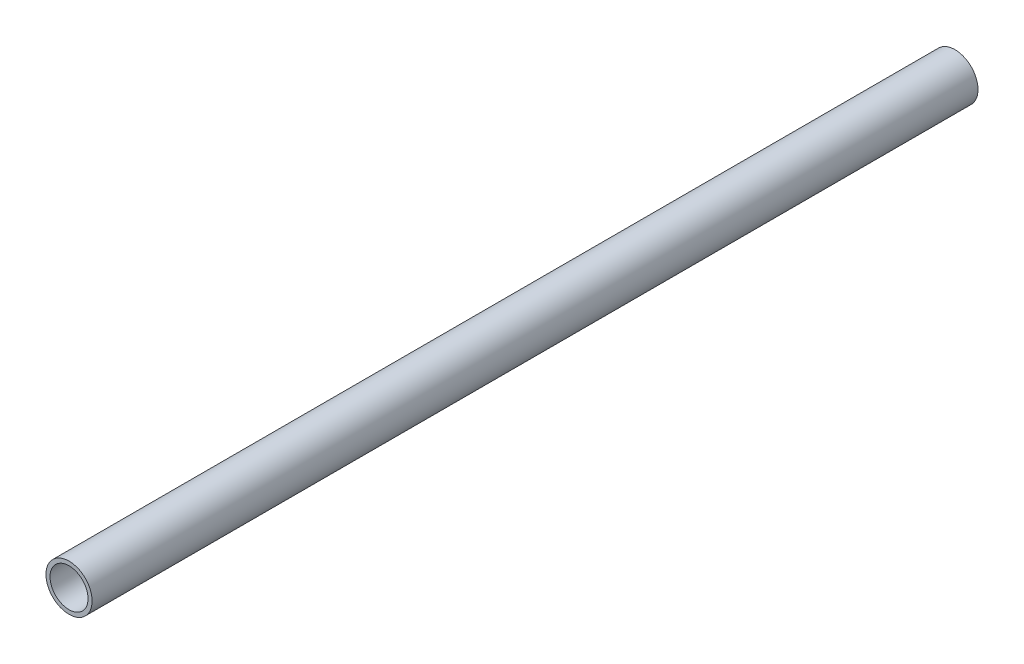
from build123d import *

# Parameters (mm, degrees)
SKETCH1_R           = 15.875
SKETCH1_R_2         = 13.081
BOSS_EXTRUDE1_DEPTH = 609.6


with BuildPart() as part:
    # Sketch1 → Boss-Extrude1 (new body)
    with BuildSketch(Plane.XY):
        Circle(SKETCH1_R)
        Circle(SKETCH1_R_2, mode=Mode.SUBTRACT)
    extrude(amount=BOSS_EXTRUDE1_DEPTH)


solid = part.part
